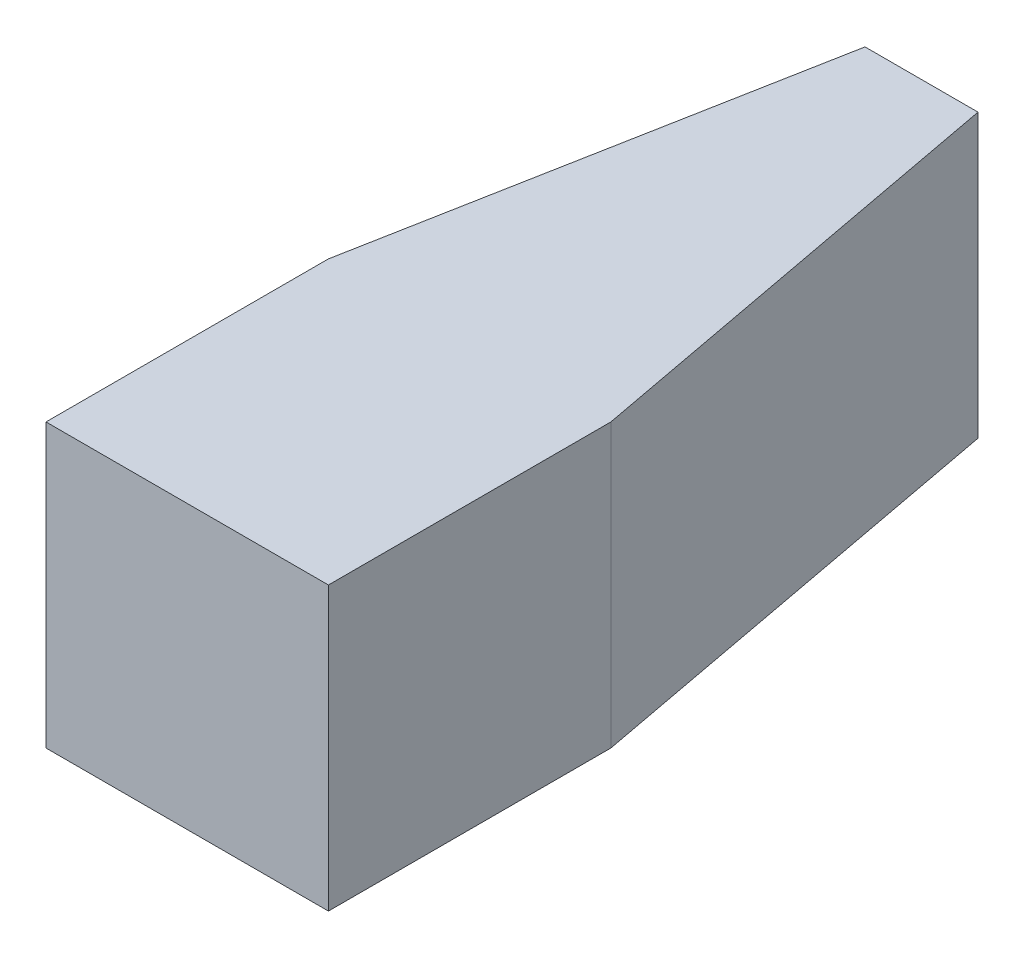
from build123d import *

# Parameters (mm, degrees)
BOSS_EXTRUDE1_DEPTH = 3.175


with BuildPart() as part:
    # Sketch1 → Boss-Extrude1 (new body)
    with BuildSketch(Plane(origin=(0, 0, 0), x_dir=(1, 0, 0), z_dir=(0, 1, 0))):
        Polygon((-3.175, 0), (0, 0), (0, 3.175), (-0.9525, 8.255), (-2.2225, 8.255), (-3.175, 3.175), align=None)
    extrude(amount=BOSS_EXTRUDE1_DEPTH)


solid = part.part
